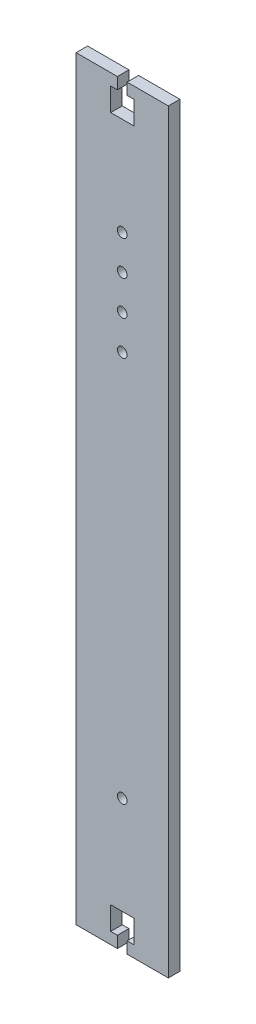
from build123d import *

# Parameters (mm, degrees)
SKETCH1_W           = 40
SKETCH1_H           = 327.5
BOSS_EXTRUDE1_DEPTH = 5
SKETCH2_R           = 2.1
CUT_EXTRUDE1_DEPTH  = 5
CUT_EXTRUDE2_DEPTH  = 5


with BuildPart() as part:
    # Sketch1 → Boss-Extrude1 (new body)
    with BuildSketch(Plane.XY):
        with Locations((-20, 163.75)):
            Rectangle(SKETCH1_W, SKETCH1_H)
    extrude(amount=BOSS_EXTRUDE1_DEPTH)

    # Sketch2 → Cut-Extrude1 (cut)
    with BuildSketch(Plane(origin=(0, 0, 0), x_dir=(-1, 0, 0), z_dir=(0, 0, -1))):
        with Locations((20, 57.5)):
            Circle(SKETCH2_R)
        with Locations((20, 270)):
            Circle(SKETCH2_R)
        with Locations((20, 255)):
            Circle(SKETCH2_R)
        with Locations((20, 240)):
            Circle(SKETCH2_R)
        with Locations((20, 225)):
            Circle(SKETCH2_R)
    extrude(amount=-CUT_EXTRUDE1_DEPTH, mode=Mode.SUBTRACT)

    # Sketch3 → Cut-Extrude2 (cut)
    with BuildSketch(Plane(origin=(0, 0, 0), x_dir=(-1, 0, 0), z_dir=(0, 0, -1))):
        Polygon((17.9, 0), (22.1, 0), (22.1, 5), (25, 5), (25, 15), (15, 15), (15, 5), (17.9, 5), align=None)
    cut_extrude2 = extrude(amount=-CUT_EXTRUDE2_DEPTH, mode=Mode.SUBTRACT)

    # Mirror1: Cut-Extrude2 across plane
    add(cut_extrude2.mirror(Plane.ZX.offset(163.75)), mode=Mode.SUBTRACT)


solid = part.part
